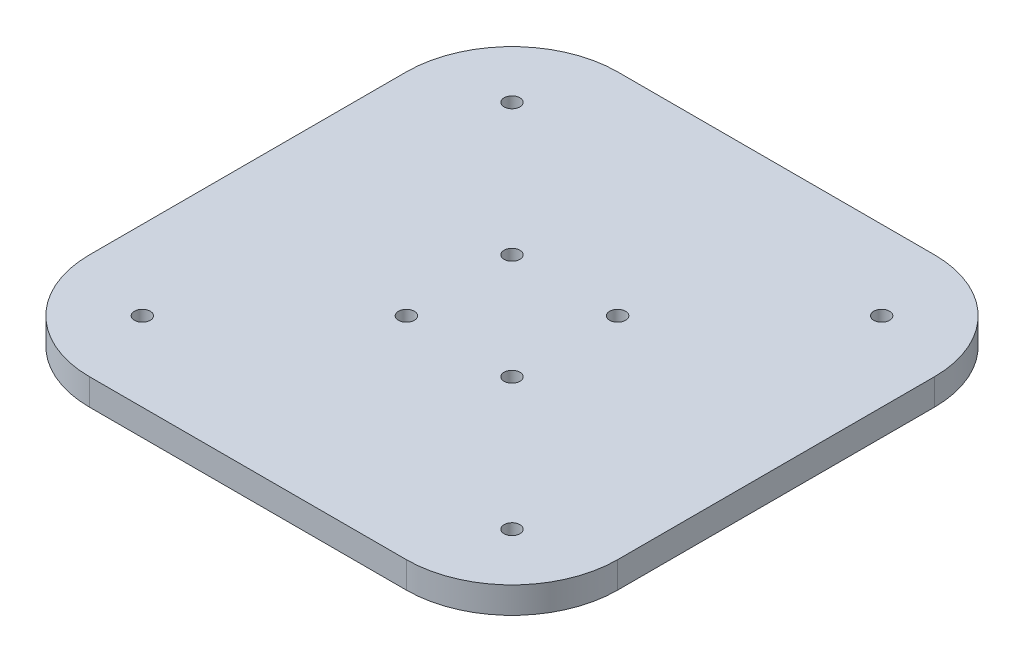
from build123d import *

# Parameters (mm, degrees)
SKETCH_1_W      = 100
SKETCH_1_H      = 100
SKETCH_1_R      = 1.5
EXTRUDE_1_DEPTH = 5
FILLET_1_R      = 20


with BuildPart() as part:
    # 草图1 → 凸台-拉伸1 (new body)
    with BuildSketch(Plane(origin=(0, 0, 0), x_dir=(1, 0, 0), z_dir=(0, 1, 0))):
        Rectangle(SKETCH_1_W, SKETCH_1_H)
        with Locations((-35, 35)):
            Circle(SKETCH_1_R, mode=Mode.SUBTRACT)
        with Locations((35, 35)):
            Circle(SKETCH_1_R, mode=Mode.SUBTRACT)
        with Locations((35, -35)):
            Circle(SKETCH_1_R, mode=Mode.SUBTRACT)
        with Locations((-35, -35)):
            Circle(SKETCH_1_R, mode=Mode.SUBTRACT)
        with Locations((-10, 10)):
            Circle(SKETCH_1_R, mode=Mode.SUBTRACT)
        with Locations((10, 10)):
            Circle(SKETCH_1_R, mode=Mode.SUBTRACT)
        with Locations((10, -10)):
            Circle(SKETCH_1_R, mode=Mode.SUBTRACT)
        with Locations((-10, -10)):
            Circle(SKETCH_1_R, mode=Mode.SUBTRACT)
    extrude(amount=EXTRUDE_1_DEPTH)

    # 圆角1
    fillet_1_edges = [part.edges().sort_by_distance(p)[0] for p in [
        (-50, 2.5, -50),
        (50, 2.5, -50),
        (50, 2.5, 50),
        (-50, 2.5, 50),
    ]]
    fillet(fillet_1_edges, radius=FILLET_1_R)


solid = part.part
